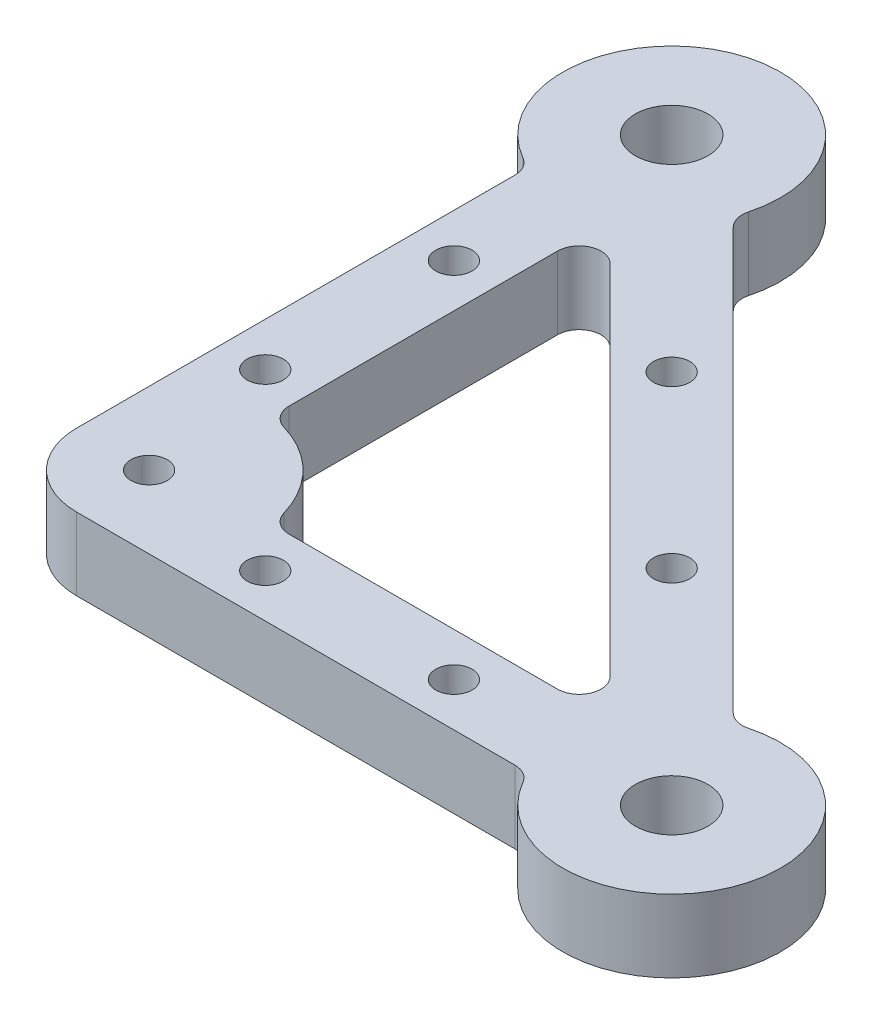
from build123d import *

# Parameters (mm, degrees)
SKETCH2_R           = 5
SKETCH2_R_2         = 2.5
BOSS_EXTRUDE1_DEPTH = 10
FILLET1_R           = 10
FILLET2_R           = 3
FILLET3_R           = 3
FILLET4_R           = 3


with BuildPart() as part:
    # Sketch2 → Boss-Extrude1 (new body)
    with BuildSketch(Plane(origin=(0, 0, 0), x_dir=(1, 0, 0), z_dir=(0, 1, 0))):
        with BuildLine():
            Line((66.252272915, -86), (-6, -86))
            Line((-6, -86), (-6, -13.747727085))
            ThreePointArc((-6, -13.747727085), (-5.740251485, 13.858192988), (13.963751735, -5.47847036))
            Line((13.963751735, -5.47847036), (74.52152964, -66.036248265))
            ThreePointArc((74.52152964, -66.036248265), (93.858192988, -85.740251485), (66.252272915, -86))
        make_face()
        Circle(SKETCH2_R, mode=Mode.SUBTRACT)
        with Locations((80, -80)):
            Circle(SKETCH2_R, mode=Mode.SUBTRACT)
        with Locations((50, -80)):
            Circle(SKETCH2_R_2, mode=Mode.SUBTRACT)
        with Locations((24, -80)):
            Circle(SKETCH2_R_2, mode=Mode.SUBTRACT)
        with Locations((0, -56)):
            Circle(SKETCH2_R_2, mode=Mode.SUBTRACT)
        with Locations((0, -30)):
            Circle(SKETCH2_R_2, mode=Mode.SUBTRACT)
        with Locations((28.284271247, -28.284271247)):
            Circle(SKETCH2_R_2, mode=Mode.SUBTRACT)
        with Locations((51.715728753, -51.715728753)):
            Circle(SKETCH2_R_2, mode=Mode.SUBTRACT)
        with Locations((4, -76)):
            Circle(SKETCH2_R_2, mode=Mode.SUBTRACT)
        with BuildLine():
            Line((65.514718626, -74), (18.866068747, -74))
            ThreePointArc((18.866068747, -74), (14.606601718, -65.393398282), (6, -61.133931253))
            Line((6, -61.133931253), (6, -14.485281374))
            Line((6, -14.485281374), (65.514718626, -74))
        make_face(mode=Mode.SUBTRACT)
    extrude(amount=BOSS_EXTRUDE1_DEPTH)

    # Fillet1
    fillet1_edges = [part.edges().sort_by_distance(p)[0] for p in [
        (-6, 5, 86),
    ]]
    fillet(fillet1_edges, radius=FILLET1_R)

    # Fillet2
    fillet2_edges = [part.edges().sort_by_distance(p)[0] for p in [
        (-6, 5, 13.747727085),
        (13.963751735, 5, 5.47847036),
        (74.52152964, 5, 66.036248265),
        (66.252272915, 5, 86),
    ]]
    fillet(fillet2_edges, radius=FILLET2_R)

    # Fillet3
    fillet3_edges = [part.edges().sort_by_distance(p)[0] for p in [
        (65.514718626, 5, 74),
        (6, 5, 14.485281374),
    ]]
    fillet(fillet3_edges, radius=FILLET3_R)

    # Fillet4
    fillet4_edges = [part.edges().sort_by_distance(p)[0] for p in [
        (6, 5, 61.133931253),
        (18.866068747, 5, 74),
    ]]
    fillet(fillet4_edges, radius=FILLET4_R)


solid = part.part
